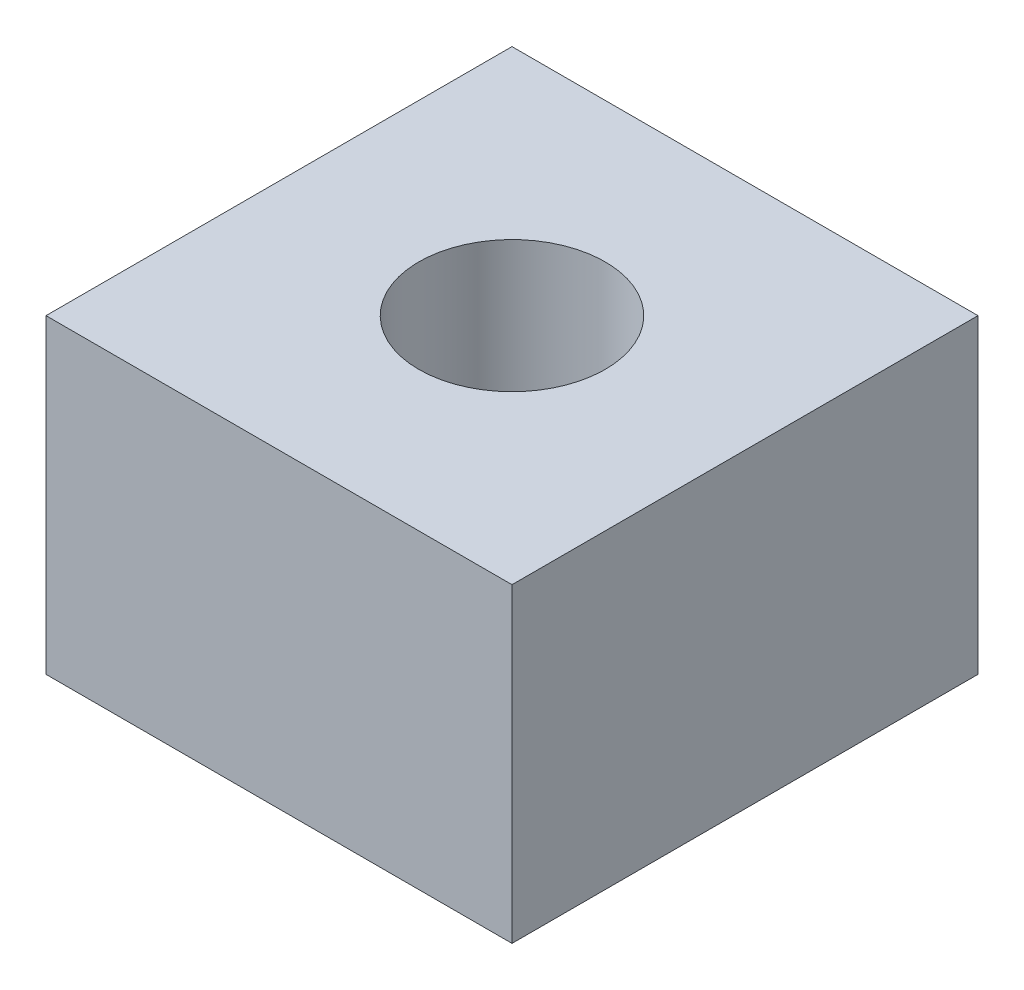
from build123d import *

# Parameters (mm, degrees)
SKETCH1_W           = 30
SKETCH1_H           = 20
BOSS_EXTRUDE1_DEPTH = 30
SKETCH3_R           = 6
CUT_EXTRUDE1_DEPTH  = 21


with BuildPart() as part:
    # Sketch1 → Boss-Extrude1 (new body)
    with BuildSketch(Plane.XY):
        with Locations((-4.781430238, -17.775295883)):
            Rectangle(SKETCH1_W, SKETCH1_H)
    extrude(amount=BOSS_EXTRUDE1_DEPTH)

    # Sketch3 → Cut-Extrude1 (cut, through all)
    with BuildSketch(Plane(origin=(0, -7.775295883, 0), x_dir=(1, 0, 0), z_dir=(0, 1, 0))):
        with Locations((-4.781430238, -15)):
            Circle(SKETCH3_R)
    extrude(amount=-CUT_EXTRUDE1_DEPTH, mode=Mode.SUBTRACT)


solid = part.part
